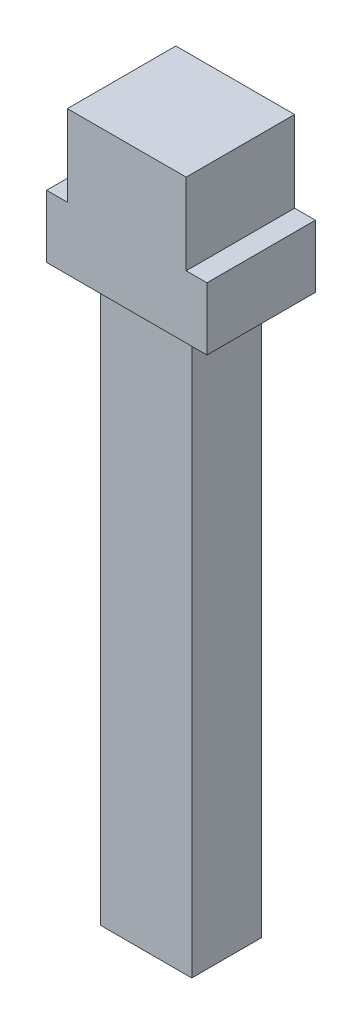
from build123d import *

# Parameters (mm, degrees)
BOSS_EXTRUDE1_DEPTH = 21
SKETCH2_R           = 2.332714882
CUT_EXTRUDE1_DEPTH  = 11
CUT_EXTRUDE2_REACH  = 26.37
SKETCH3_W           = 3.734340962
SKETCH3_H           = 109.655613693


with BuildPart() as part:
    # Sketch1 → Boss-Extrude1 (new body)
    with BuildSketch(Plane.XY):
        Polygon((11.4999958, -2.86166347), (11.4999958, 12.851204158), (-11.4999958, 12.831547243), (-11.4999958, -2.86166347), (-15.520087877, -2.86166347), (-15.520087877, -14.967378119), (-11.520087877, -14.967378119), (-8.849574745, -14.967378119), (-8.849574745, -124.622991812), (8.849574745, -124.622991812), (8.849574745, -14.967378119), (11.520087877, -14.967378119), (15.520087877, -14.967378119), (15.520087877, -2.86166347), align=None)
    extrude(amount=BOSS_EXTRUDE1_DEPTH)

    # Sketch2 → Cut-Extrude1 (cut)
    with BuildSketch(Plane.XZ.offset(14.967378119)):
        with Locations((-12.184831311, 10.5)):
            Circle(SKETCH2_R)
        with Locations((12.184831311, 10.5)):
            Circle(SKETCH2_R)
    extrude(amount=-CUT_EXTRUDE1_DEPTH, mode=Mode.SUBTRACT)

    # Sketch3 → Cut-Extrude2 (cut, up to next)
    with BuildSketch(Plane.ZY.offset(8.849574745), mode=Mode.PRIVATE) as cut_extrude2_sk1:
        with Locations((19.132829519, -69.795184965)):
            Rectangle(SKETCH3_W, SKETCH3_H)
    cut_extrude2_tool1 = extrude(cut_extrude2_sk1.sketch, amount=-CUT_EXTRUDE2_REACH, mode=Mode.PRIVATE) & part.part
    add(cut_extrude2_tool1.solids().sort_by_distance((-8.849575, -69.795185, 19.13283))[0], mode=Mode.SUBTRACT)
    # Sketch3 → Cut-Extrude2 (cut, up to next)
    with BuildSketch(Plane.ZY.offset(8.849574745), mode=Mode.PRIVATE) as cut_extrude2_sk2:
        with Locations((1.867170481, -69.795184965)):
            Rectangle(SKETCH3_W, SKETCH3_H)
    cut_extrude2_tool2 = extrude(cut_extrude2_sk2.sketch, amount=-CUT_EXTRUDE2_REACH, mode=Mode.PRIVATE) & part.part
    add(cut_extrude2_tool2.solids().sort_by_distance((-8.849575, -69.795185, 1.86717))[0], mode=Mode.SUBTRACT)


solid = part.part
